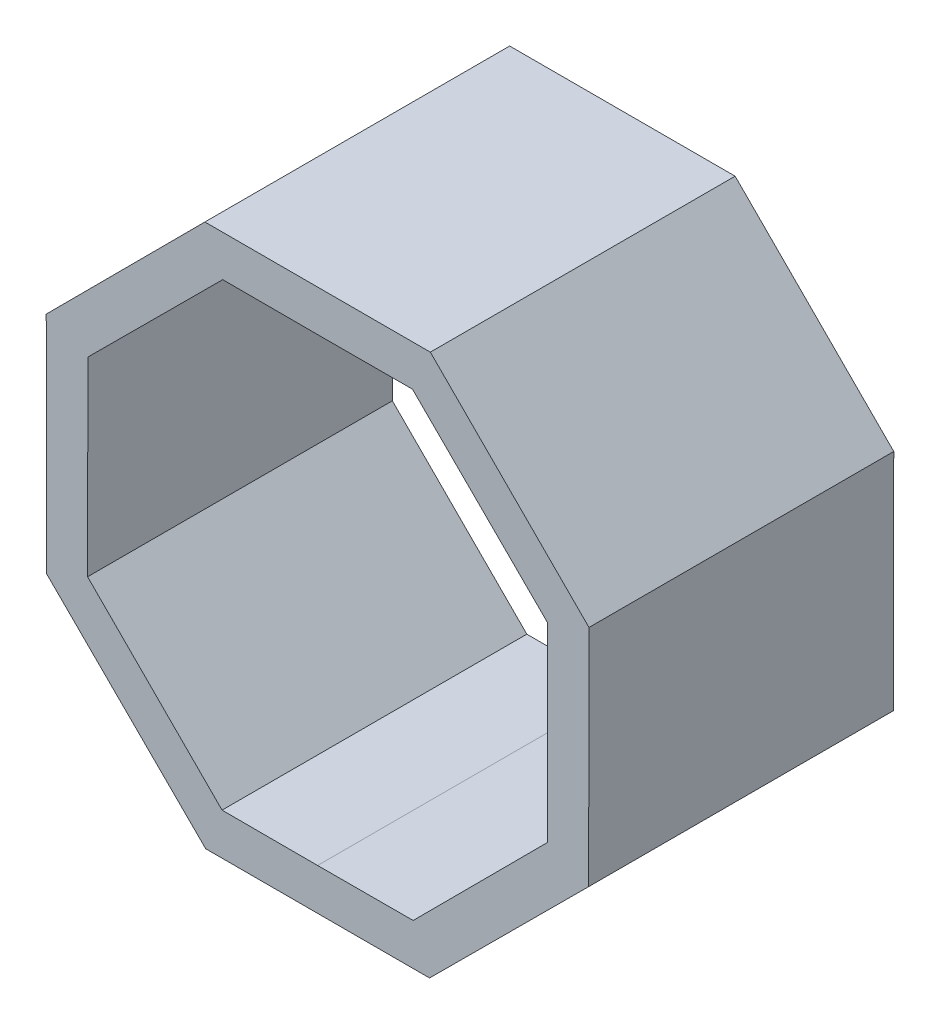
from build123d import *

# Parameters (mm, degrees)
BOSS_EXTRUDE1_DEPTH = 9.8
SKETCH2_R           = 3.949999995
BOSS_EXTRUDE2_DEPTH = 1.2
SKETCH3_W           = 38.864651583
SKETCH3_H           = 1.2
CUT_EXTRUDE1_DEPTH  = 21.999977365
BOSS_EXTRUDE3_DEPTH = 2


with BuildPart() as part:
    # Sketch1 → Boss-Extrude1 (new body)
    with BuildSketch(Plane.XY.offset(11)):
        Polygon((4.333958961, -10.506317019), (10.493660346, -4.364516586), (10.506317019, 4.333958961), (4.364516586, 10.493660346), (-4.364516586, 10.493660346), (-10.506317019, 4.333958961), (-10.493660346, -4.364516586), (-4.333958961, -10.506317019), align=None)
        Polygon((0, 8.900009778), (3.673546249, 8.905354887), (8.894626983, 3.699447494), (8.905354887, -3.673546249), (3.699447494, -8.894626983), (0, -8.900009778), (-3.699447494, -8.894626983), (-8.905354887, -3.673546249), (-8.894626983, 3.699447494), (-3.673546249, 8.905354887), align=None, mode=Mode.SUBTRACT)
    extrude(amount=-BOSS_EXTRUDE1_DEPTH)

    # Sketch2 → Boss-Extrude2 (add)
    with BuildSketch(Plane(origin=(0, 0, 1.2), x_dir=(-1, 0, 0), z_dir=(0, 0, -1))):
        with BuildLine():
            Line((4.364516586, 10.493660346), (-4.364516586, 10.493660346))
            Line((-4.364516586, 10.493660346), (-10.506317019, 4.333958961))
            ThreePointArc((-10.506317019, 4.333958961), (-14.560364187, -0.021186842), (-10.493660346, -4.364516586))
            Line((-10.493660346, -4.364516586), (-4.333958961, -10.506317019))
            Line((-4.333958961, -10.506317019), (4.333958961, -10.506317019))
            Line((4.333958961, -10.506317019), (10.493660346, -4.364516586))
            ThreePointArc((10.493660346, -4.364516586), (14.560364187, -0.021186842), (10.506317019, 4.333958961))
            Line((10.506317019, 4.333958961), (4.364516586, 10.493660346))
        make_face()
        Circle(SKETCH2_R, mode=Mode.SUBTRACT)
    extrude(amount=BOSS_EXTRUDE2_DEPTH)

    # Sketch3 → Cut-Extrude1 (cut, through all)
    with BuildSketch(Plane.XZ.offset(10.506317019)):
        with Locations((0.864726488, 0.6)):
            Rectangle(SKETCH3_W, SKETCH3_H)
    extrude(amount=-CUT_EXTRUDE1_DEPTH, mode=Mode.SUBTRACT)

    # Sketch5 → Boss-Extrude3 (add)
    with BuildSketch(Plane(origin=(0, 0, 1.2), x_dir=(-1, 0, 0), z_dir=(0, 0, -1))):
        Polygon((-4.364516586, 10.493660346), (-10.506317019, 4.333958961), (-10.493660346, -4.364516586), (-4.333958961, -10.506317019), (4.333958961, -10.506317019), (10.493660346, -4.364516586), (10.506317019, 4.333958961), (4.364516586, 10.493660346), align=None)
        Polygon((-8.894626983, 3.699447494), (-8.905354887, -3.673546249), (-3.699447494, -8.894626983), (0, -8.900009778), (3.699447494, -8.894626983), (8.905354887, -3.673546249), (8.894626983, 3.699447494), (3.673546249, 8.905354887), (0, 8.900009778), (-3.673546249, 8.905354887), align=None, mode=Mode.SUBTRACT)
    extrude(amount=BOSS_EXTRUDE3_DEPTH)


solid = part.part
